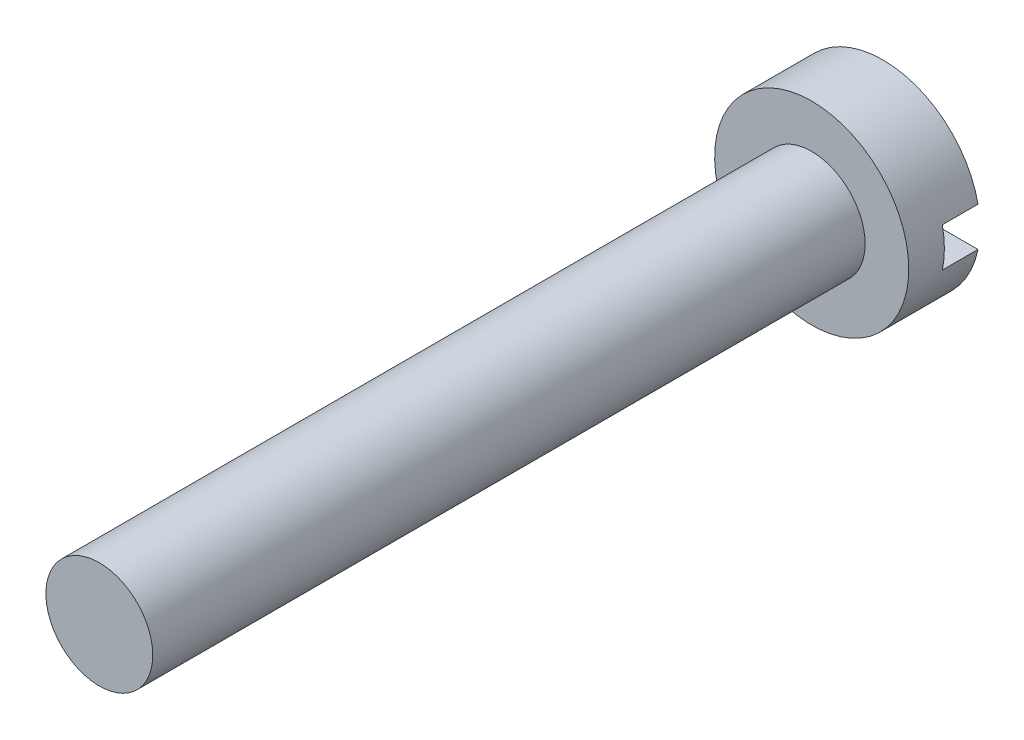
from build123d import *

# Parameters (mm, degrees)
SKETCH1_R          = 2.725
EXTRUDE1_DEPTH     = 2
CUT_EXTRUDE1_DEPTH = 1
SKETCH3_R          = 1.5
EXTRUDE2_DEPTH     = 20


with BuildPart() as part:
    # Sketch1 → Extrude1 (new body)
    with BuildSketch(Plane.XY):
        Circle(SKETCH1_R)
    extrude(amount=EXTRUDE1_DEPTH)

    # Sketch2 → Cut-Extrude1 (cut)
    with BuildSketch(Plane(origin=(0, 0, 0), x_dir=(-1, 0, 0), z_dir=(0, 0, -1))):
        Polygon((3.449801909, 0), (3.449801909, 0.55), (-3.901269584, 0.55), (-3.901269584, -0.55), (3.449801909, -0.55), align=None)
    extrude(amount=-CUT_EXTRUDE1_DEPTH, mode=Mode.SUBTRACT)

    # Sketch3 → Extrude2 (add)
    with BuildSketch(Plane.XY.offset(2)):
        Circle(SKETCH3_R)
    extrude(amount=EXTRUDE2_DEPTH)


solid = part.part
